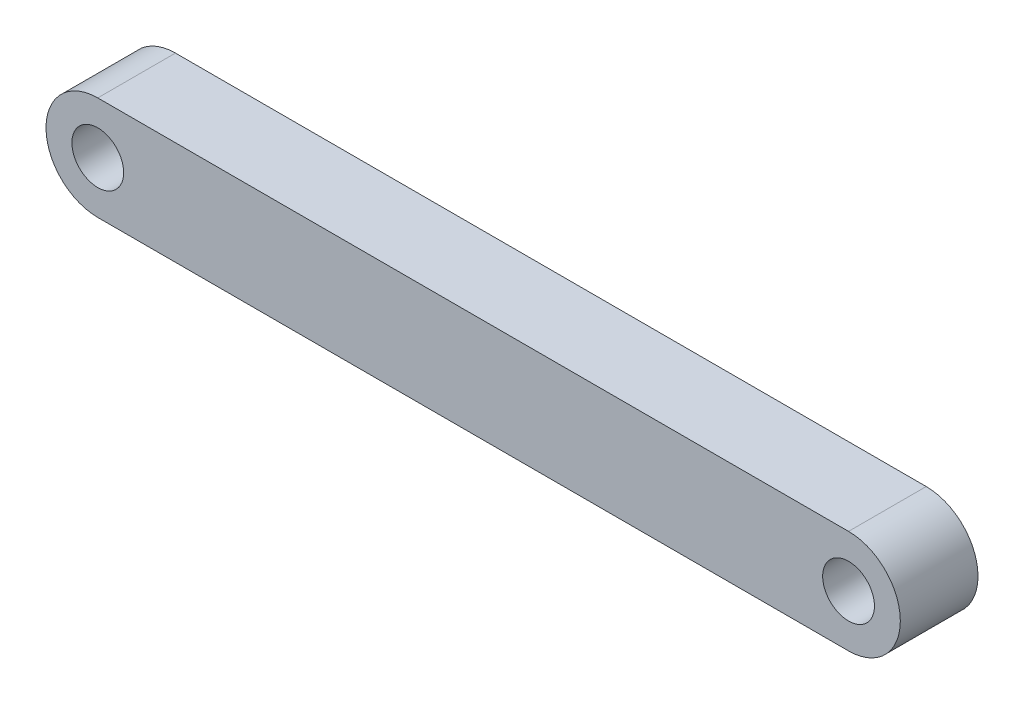
from build123d import *

# Parameters (mm, degrees)
SKETCH_1_R      = 10
EXTRUDE_1_DEPTH = 15


with BuildPart() as part:
    # Эскиз1 → Бобышка-Вытянуть1 (new body, symmetric)
    with BuildSketch(Plane.XY):
        with BuildLine():
            Line((0, 20), (-290, 20))
            ThreePointArc((-290, 20), (-310, 0), (-290, -20))
            Line((-290, -20), (0, -20))
            ThreePointArc((0, -20), (20, 0), (0, 20))
        make_face()
        with Locations((-290, 0)):
            Circle(SKETCH_1_R, mode=Mode.SUBTRACT)
        Circle(SKETCH_1_R, mode=Mode.SUBTRACT)
    extrude(amount=EXTRUDE_1_DEPTH, both=True)


solid = part.part
